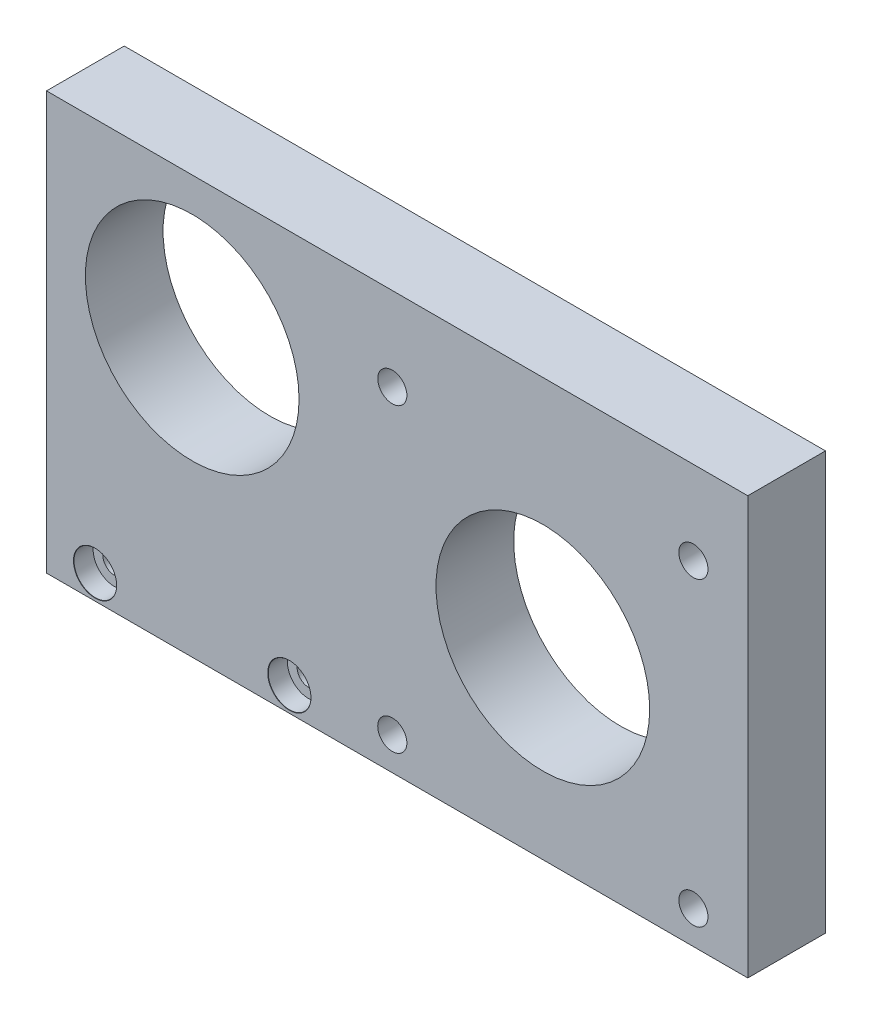
from build123d import *

# Parameters (mm, degrees)
ESBO_O1_W                        = 72.2
ESBO_O1_H                        = 43
RESSALTO_EXTRUS_O1_DEPTH         = 8
ESBO_O2_R                        = 11
ESBO_O2_R_2                      = 1.5
CORTE_EXTRUS_O1_DEPTH            = 9
REBAIXO_PARA_SHCS_M21_AT_2_COUNT = 2
REBAIXO_PARA_SHCS_M21_AT_2_PITCH = 20


with BuildPart() as part:
    # Esboço1 → Ressalto-extrusão1 (new body)
    with BuildSketch(Plane.XY):
        Rectangle(ESBO_O1_W, ESBO_O1_H)
    extrude(amount=RESSALTO_EXTRUS_O1_DEPTH)

    # Esboço2 → Corte-extrusão1 (cut, through all)
    with BuildSketch(Plane.XY.offset(8)):
        with Locations((-21.1, 7)):
            Circle(ESBO_O2_R)
        with Locations((15, -2.6)):
            Circle(ESBO_O2_R)
        with Locations((-0.5, 12.9)):
            Circle(ESBO_O2_R_2)
        with Locations((30.5, 12.9)):
            Circle(ESBO_O2_R_2)
        with Locations((30.5, -18.1)):
            Circle(ESBO_O2_R_2)
        with Locations((-0.5, -18.1)):
            Circle(ESBO_O2_R_2)
    extrude(amount=-CORTE_EXTRUS_O1_DEPTH, mode=Mode.SUBTRACT)

    # Esboço6 → Rebaixo para SHCS M21 (revolve, cut)
    with BuildSketch(Plane(origin=(-31.1, -19, 8), x_dir=(0, -1, 0), z_dir=(1, 0, 0))):
        Polygon((0, 0), (0, 8), (1.2, 8), (1.2, 2), (2.2, 2), (2.2, 0.025), (2.225, 0), align=None)
    rebaixo_para_shcs_m21 = revolve(axis=Axis((-31.1, -19, 14.35), (0, 0, -1)), mode=Mode.SUBTRACT)

    # Rebaixo para SHCS M21 at 2: Rebaixo para SHCS M21 ×2
    with Locations(*[(i * REBAIXO_PARA_SHCS_M21_AT_2_PITCH, 0, 0) for i in range(1, REBAIXO_PARA_SHCS_M21_AT_2_COUNT)]):
        add(rebaixo_para_shcs_m21, mode=Mode.SUBTRACT)


solid = part.part
